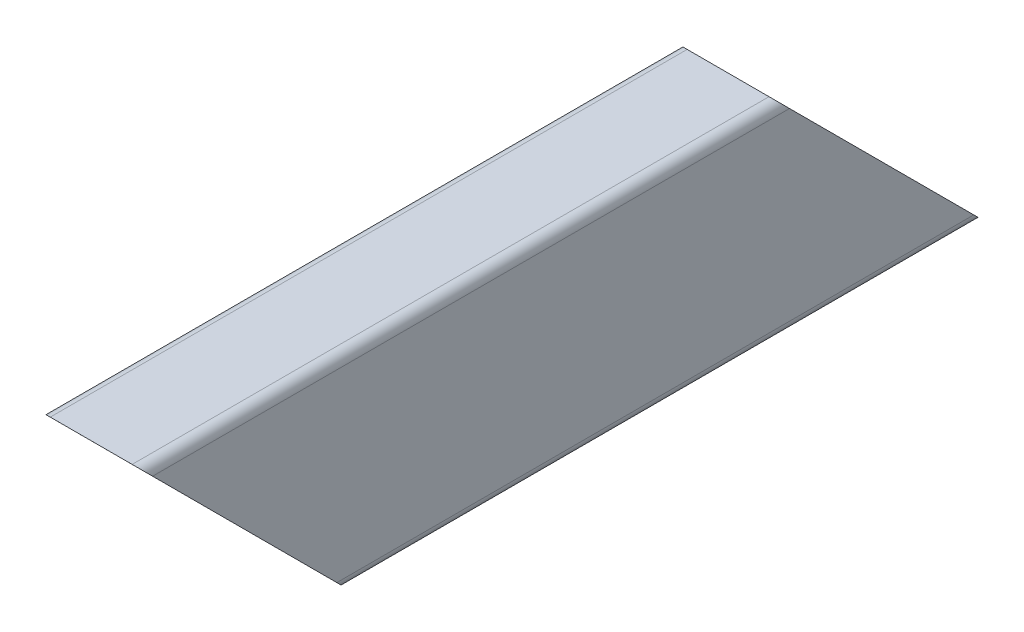
from build123d import *

# Parameters (mm, degrees)
EXTRUDE_1_DEPTH     = 205.56
CUT_EXTRUDE_1_DEPTH = 50


with BuildPart() as part:
    # Эскиз1 → Бобышка-Вытянуть1 (new body)
    with BuildSketch(Plane.XY):
        with BuildLine():
            Line((-10, 50), (10, 50))
            ThreePointArc((10, 50), (11.767766953, 49.267766953), (12.5, 47.5))
            Line((12.5, 47.5), (12.5, 2.5))
            ThreePointArc((12.5, 2.5), (11.767766953, 0.732233047), (10, 0))
            Line((10, 0), (-10, 0))
            ThreePointArc((-10, 0), (-11.767766953, 0.732233047), (-12.5, 2.5))
            Line((-12.5, 2.5), (-12.5, 47.5))
            ThreePointArc((-12.5, 47.5), (-11.767766953, 49.267766953), (-10, 50))
        make_face()
        with BuildLine():
            Line((-7.5, 47.5), (7.5, 47.5))
            ThreePointArc((7.5, 47.5), (9.267766953, 46.767766953), (10, 45))
            Line((10, 45), (10, 5))
            ThreePointArc((10, 5), (9.267766953, 3.232233047), (7.5, 2.5))
            Line((7.5, 2.5), (-7.5, 2.5))
            ThreePointArc((-7.5, 2.5), (-9.267766953, 3.232233047), (-10, 5))
            Line((-10, 5), (-10, 45))
            ThreePointArc((-10, 45), (-9.267766953, 46.767766953), (-7.5, 47.5))
        make_face(mode=Mode.SUBTRACT)
    extrude(amount=-EXTRUDE_1_DEPTH)

    # Эскиз2 → Вырез-Вытянуть1 (cut)
    with BuildSketch(Plane.ZY.offset(12.5)):
        Polygon((-205.56, 50), (-155.559999999, 50), (-205.56, 0), align=None)
        Polygon((0.003491861, 0), (-49.996508139, 0), (0.003491861, 49.999999999), align=None)
    extrude(amount=-CUT_EXTRUDE_1_DEPTH, mode=Mode.SUBTRACT)


solid = part.part
